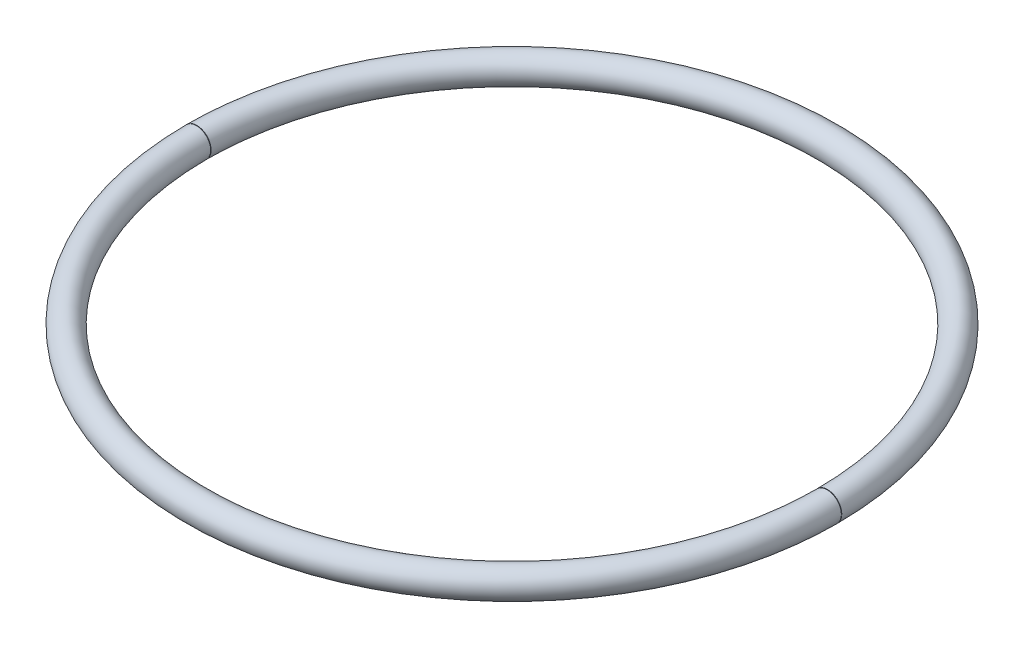
from build123d import *

# Parameters (mm, degrees)
SWEEP4_PROFILE_R        = 25.4
SHELL2_T                = -3.175
SKETCH27_W              = 101.6
SKETCH27_H              = 0.757976
CUT_EXTRUDE1_DEPTH      = 26.4
CUT_EXTRUDE1_DEPTH_BACK = 26.4


with BuildPart() as part:
    # Sweep4: sweep along a path in Sketch26
    with BuildLine(Plane(origin=(0, 0, 0), x_dir=(1, 0, 0), z_dir=(0, 1, 0))) as sweep4_path:
        ThreePointArc((563.56236, 0.396875), (-563.5625, 0), (563.56236, -0.396875))
    # Sweep4 profile (on start of the path) → Sweep4 (sweep)
    with BuildSketch(Plane(origin=(563.56236, 0, -0.396875), x_dir=(-1, 0, 0.000704), z_dir=(-0.000704, 0, -1))):
        Circle(SWEEP4_PROFILE_R)
    sweep(path=sweep4_path.line)

    # Shell2
    shell2_openings = [part.faces().sort_by_distance(p)[0] for p in [
        (538.162367, 0, 0.378988),
        (538.162367, 0, -0.378988),
    ]]
    offset(amount=SHELL2_T, openings=shell2_openings, kind=Kind.INTERSECTION)

    # Sketch27 → Cut-Extrude1 (cut, two sides)
    with BuildSketch(Plane(origin=(0, 0, 0), x_dir=(1, 0, 0), z_dir=(0, 1, 0))) as cut_extrude1_sk:
        with Locations((-558.8, 0)):
            Rectangle(SKETCH27_W, SKETCH27_H)
    extrude(amount=CUT_EXTRUDE1_DEPTH, mode=Mode.SUBTRACT)
    extrude(cut_extrude1_sk.sketch, amount=-CUT_EXTRUDE1_DEPTH_BACK, mode=Mode.SUBTRACT)


solid = part.part
